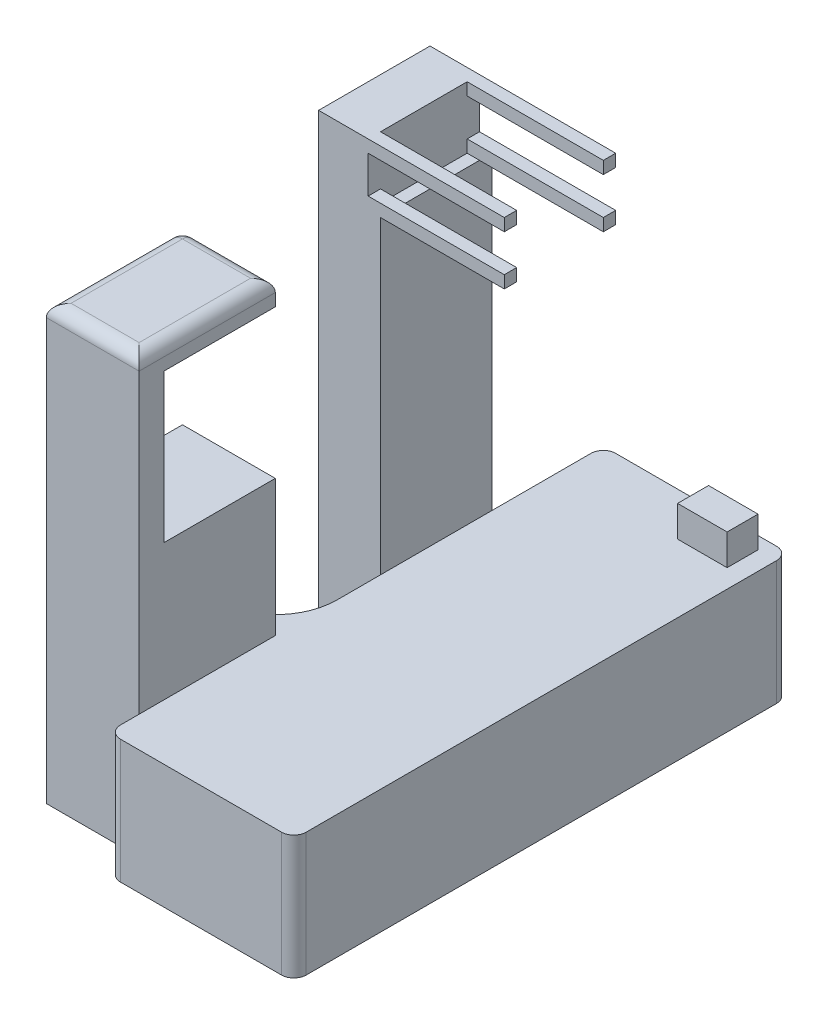
from build123d import *

# Parameters (mm, degrees)
SKETCH5_W            = 30
SKETCH5_H            = 80
BOSS_EXTRUDE4_DEPTH  = 20
SKETCH6_W            = 8
SKETCH6_H            = 5
BOSS_EXTRUDE5_DEPTH  = 5
SKETCH9_W            = 15
SKETCH9_H            = 22
BOSS_EXTRUDE10_DEPTH = 70
SKETCH14_W           = 15
SKETCH14_H           = 24
CUT_EXTRUDE1_DEPTH   = 18
FILLET1_R            = 2
FILLET2_R            = 10
FILLET4_R            = 2
FILLET6_R            = 2
SKETCH18_W           = 10
SKETCH18_H           = 18
BOSS_EXTRUDE11_DEPTH = 80
BOSS_EXTRUDE12_DEPTH = 10
CUT_EXTRUDE4_DEPTH   = 22


with BuildPart() as part:
    # Sketch5 → Boss-Extrude4 (new body)
    with BuildSketch(Plane(origin=(0, 0, 0), x_dir=(1, 0, 0), z_dir=(0, 1, 0))):
        Rectangle(SKETCH5_W, SKETCH5_H)
    extrude(amount=BOSS_EXTRUDE4_DEPTH)

    # Sketch6 → Boss-Extrude5 (add)
    with BuildSketch(Plane(origin=(0, 20, 0), x_dir=(1, 0, 0), z_dir=(0, 1, 0))):
        with Locations((8, 35.5)):
            Rectangle(SKETCH6_W, SKETCH6_H)
    extrude(amount=BOSS_EXTRUDE5_DEPTH)

    # Sketch9 → Boss-Extrude10 (add)
    with BuildSketch(Plane(origin=(0, 0, 0), x_dir=(1, 0, 0), z_dir=(0, 1, 0))):
        with Locations((-22.5, -24)):
            Rectangle(SKETCH9_W, SKETCH9_H)
    extrude(amount=BOSS_EXTRUDE10_DEPTH)

    # Sketch14 → Cut-Extrude1 (cut)
    with BuildSketch(Plane(origin=(0, 0, 13), x_dir=(-1, 0, 0), z_dir=(0, 0, -1))):
        with Locations((22.5, 54)):
            Rectangle(SKETCH14_W, SKETCH14_H)
    extrude(amount=-CUT_EXTRUDE1_DEPTH, mode=Mode.SUBTRACT)

    # Fillet1
    fillet1_edges = [part.edges().sort_by_distance(p)[0] for p in [
        (-15, 10, -40),
        (15, 10, -40),
        (15, 10, 40),
        (-15, 10, 40),
    ]]
    fillet(fillet1_edges, radius=FILLET1_R)

    # Fillet2
    fillet2_edges = [part.edges().sort_by_distance(p)[0] for p in [
        (-15, 10, 13),
    ]]
    fillet(fillet2_edges, radius=FILLET2_R)

    # Fillet4
    fillet4_edges = [part.edges().sort_by_distance(p)[0] for p in [
        (-30, 68, 13),
    ]]
    fillet(fillet4_edges, radius=FILLET4_R)

    # Fillet6
    fillet6_edges = [part.edges().sort_by_distance(p)[0] for p in [
        (-22.5, 70, 35),
        (-30, 70, 25),
        (-15, 70, 24),
        (-21.5, 70, 13),
        (-29.414213562, 70, 13.585786438),
    ]]
    fillet(fillet6_edges, radius=FILLET6_R)

    # Sketch18 → Boss-Extrude11 (add)
    with BuildSketch(Plane(origin=(0, 0, 0), x_dir=(-1, 0, 0), z_dir=(0, -1, 0))):
        with Locations((20, 13)):
            Rectangle(SKETCH18_W, SKETCH18_H)
    extrude(amount=-BOSS_EXTRUDE11_DEPTH)

    # Sketch19 → Boss-Extrude12 (add)
    with BuildSketch(Plane(origin=(0, 80, 0), x_dir=(1, 0, 0), z_dir=(0, 1, 0))):
        Polygon((-15, 22), (5, 22), (5, 14.741263634), (5, 6.741263634), (5, 4), (-15, 4), (-15, 6.741263634), (-15, 14.741263634), align=None)
    extrude(amount=-BOSS_EXTRUDE12_DEPTH)

    # Sketch20 → Cut-Extrude4 (cut)
    with BuildSketch(Plane(origin=(5, 0, 0), x_dir=(0, 0, -1), z_dir=(1, 0, 0))):
        Polygon((20, 80), (6, 80), (6, 78), (4, 78), (4, 72), (6, 72), (6, 70), (20, 70), (20, 72), (22, 72), (22, 78), (20, 78), align=None)
    extrude(amount=-CUT_EXTRUDE4_DEPTH, mode=Mode.SUBTRACT)


solid = part.part
